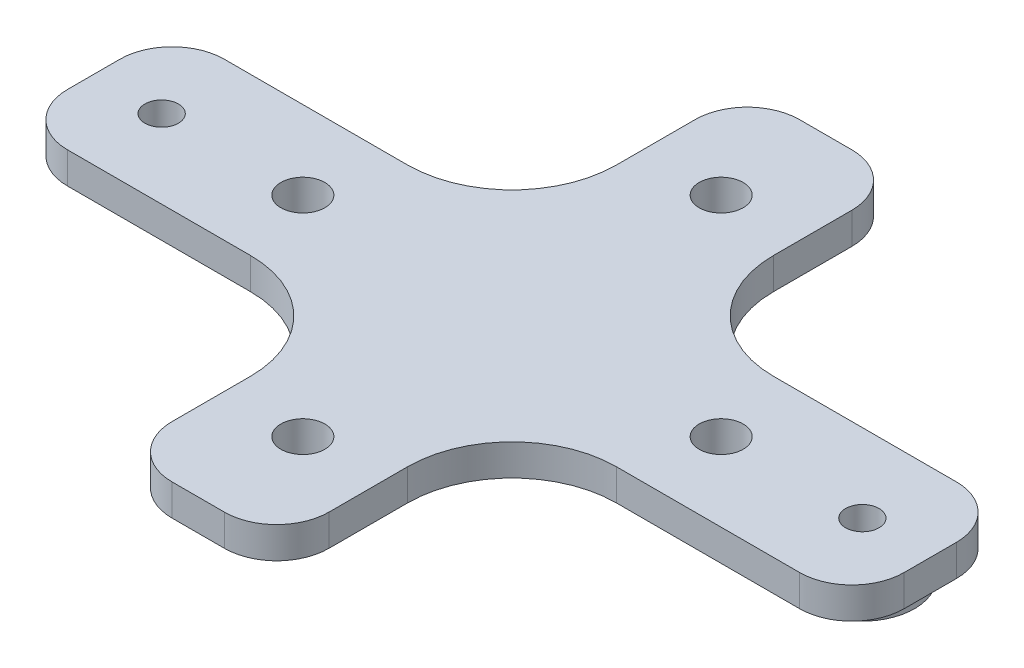
from build123d import *

# Parameters (mm, degrees)
SKETCH_2_W          = 80
SKETCH_2_H          = 15
EXTRUDE_1_DEPTH     = 3
SKETCH_1_R          = 5
EXTRUDE_2_DEPTH     = 2
SKETCH_3_W          = 15
SKETCH_3_H          = 60
EXTRUDE_3_DEPTH     = 3
SKETCH_4_R          = 2.1
CUT_EXTRUDE_4_DEPTH = 4
SKETCH_5_R          = 2.1
CUT_EXTRUDE_5_DEPTH = 4
FILLET_2_R          = 5
SKETCH_6_R          = 1.6
CUT_EXTRUDE_6_DEPTH = 6
FILLET_3_R          = 10


with BuildPart() as part:
    # 草圖2 → 填料-伸長1 (new body)
    with BuildSketch(Plane(origin=(0, 0, 0), x_dir=(1, 0, 0), z_dir=(0, 1, 0))):
        Rectangle(SKETCH_2_W, SKETCH_2_H)
    extrude(amount=EXTRUDE_1_DEPTH)

    # 草圖1 → 填料-伸長2 (add)
    with BuildSketch(Plane(origin=(0, 0, 0), x_dir=(1, 0, 0), z_dir=(0, 1, 0))):
        with Locations((-33.5, 0)):
            Circle(SKETCH_1_R)
        with Locations((33.5, 0)):
            Circle(SKETCH_1_R)
    extrude(amount=-EXTRUDE_2_DEPTH)

    # 草圖3 → 填料-伸長3 (add)
    with BuildSketch(Plane.XZ):
        Rectangle(SKETCH_3_W, SKETCH_3_H)
    extrude(amount=-EXTRUDE_3_DEPTH)

    # 草圖4 → 除料-伸長4 (cut, through all)
    with BuildSketch(Plane.XZ):
        with Locations((0, 20)):
            Circle(SKETCH_4_R)
        with Locations((0, -20)):
            Circle(SKETCH_4_R)
    extrude(amount=-CUT_EXTRUDE_4_DEPTH, mode=Mode.SUBTRACT)

    # 草圖5 → 除料-伸長5 (cut, through all)
    with BuildSketch(Plane.XZ):
        with Locations((-20, 0)):
            Circle(SKETCH_5_R)
        with Locations((20, 0)):
            Circle(SKETCH_5_R)
    extrude(amount=-CUT_EXTRUDE_5_DEPTH, mode=Mode.SUBTRACT)

    # 圓角2
    fillet_2_edges = [part.edges().sort_by_distance(p)[0] for p in [
        (7.5, 1.5, 30),
        (-7.5, 1.5, -30),
        (7.5, 1.5, -30),
        (-7.5, 1.5, 30),
        (40, 1.5, 7.5),
        (-40, 1.5, 7.5),
        (-40, 1.5, -7.5),
        (40, 1.5, -7.5),
    ]]
    fillet(fillet_2_edges, radius=FILLET_2_R)

    # 草圖6 → 除料-伸長6 (cut, through all)
    with BuildSketch(Plane.XZ.offset(2)):
        with Locations((-33.5, 0)):
            Circle(SKETCH_6_R)
        with Locations((33.5, 0)):
            Circle(SKETCH_6_R)
    extrude(amount=-CUT_EXTRUDE_6_DEPTH, mode=Mode.SUBTRACT)

    # 圓角3
    fillet_3_edges = [part.edges().sort_by_distance(p)[0] for p in [
        (7.5, 1.5, -7.5),
        (7.5, 1.5, 7.5),
        (-7.5, 1.5, -7.5),
        (-7.5, 1.5, 7.5),
    ]]
    fillet(fillet_3_edges, radius=FILLET_3_R)


solid = part.part
